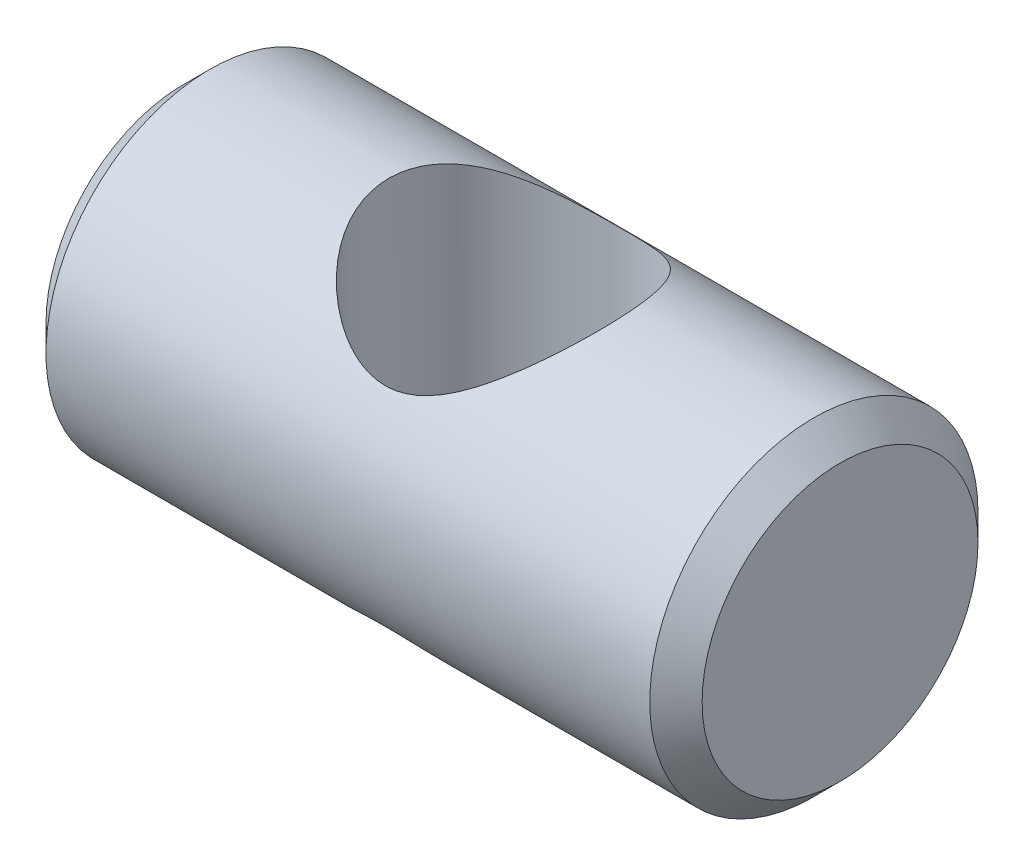
from build123d import *

# Parameters (mm, degrees)
CROQUIS1_R                 = 4.765
SALIENTE_EXTRUIR1_DEPTH    = 9.525
CHAFL_N1_SIZE              = 0.76
CROQUIS2_R                 = 3.43
CORTAR_EXTRUIR1_DEPTH      = 5.765
CORTAR_EXTRUIR1_DEPTH_BACK = 5.765


with BuildPart() as part:
    # Croquis1 → Saliente-Extruir1 (new body, symmetric)
    with BuildSketch(Plane(origin=(0, 0, 0), x_dir=(0, 0, -1), z_dir=(1, 0, 0))):
        Circle(CROQUIS1_R)
    extrude(amount=SALIENTE_EXTRUIR1_DEPTH, both=True)

    # Chaflán1
    chafl_n1_edges = [part.edges().sort_by_distance(p)[0] for p in [
        (-9.525, 0, 4.765),
        (9.525, 0, 4.765),
    ]]
    chamfer(chafl_n1_edges, length=CHAFL_N1_SIZE)

    # Croquis2 → Cortar-Extruir1 (cut, two sides)
    with BuildSketch(Plane(origin=(0, 0, 0), x_dir=(1, 0, 0), z_dir=(0, 1, 0))) as cortar_extruir1_sk:
        with Locations((0, -0.25)):
            Circle(CROQUIS2_R)
    extrude(amount=CORTAR_EXTRUIR1_DEPTH, mode=Mode.SUBTRACT)
    extrude(cortar_extruir1_sk.sketch, amount=-CORTAR_EXTRUIR1_DEPTH_BACK, mode=Mode.SUBTRACT)


solid = part.part
